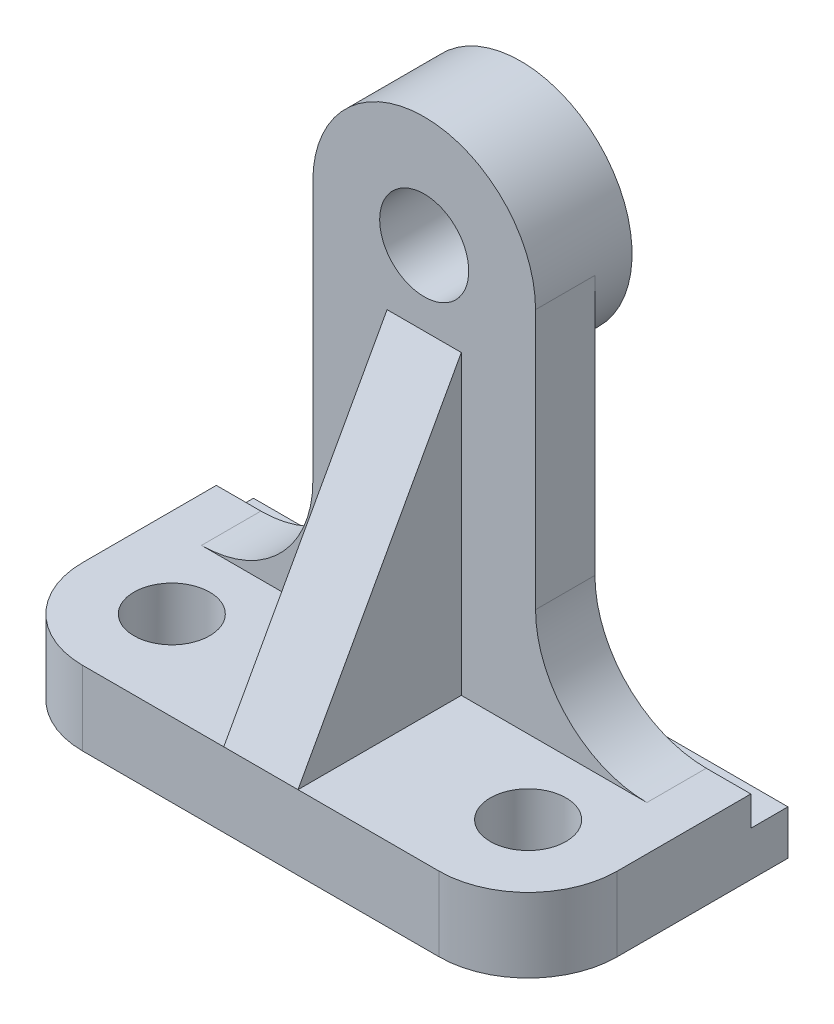
from build123d import *

# Parameters (mm, degrees)
SKETCH1_W           = 72
SKETCH1_H           = 35
BOSS_EXTRUDE1_DEPTH = 10
FILLET1_R           = 12
SKETCH2_W           = 5
SKETCH2_H           = 4
CUT_EXTRUDE1_DEPTH  = 75.767974428
SKETCH3_R           = 6
BOSS_EXTRUDE2_DEPTH = 8
FILLET2_R           = 15
FILLET3_R           = 15
M12_TAPPED_HOLE1_D  = 10.2
SKETCH7_R           = 15
SKETCH7_R_2         = 6
BOSS_EXTRUDE3_DEPTH = 5
RIB1_REACH          = 87.013
SKETCH8_WALL_W      = 217.67731737
SKETCH8_WALL_H      = 10


with BuildPart() as part:
    # Sketch1 → Boss-Extrude1 (new body)
    with BuildSketch(Plane(origin=(0, 0, 0), x_dir=(1, 0, 0), z_dir=(0, 1, 0))):
        Rectangle(SKETCH1_W, SKETCH1_H)
    extrude(amount=BOSS_EXTRUDE1_DEPTH)

    # Fillet1
    fillet1_edges = [part.edges().sort_by_distance(p)[0] for p in [
        (36, 5, 17.5),
        (-36, 5, 17.5),
    ]]
    fillet(fillet1_edges, radius=FILLET1_R)

    # Sketch2 → Cut-Extrude1 (cut, through all)
    with BuildSketch(Plane(origin=(36, 0, 0), x_dir=(0, 0, -1), z_dir=(1, 0, 0))):
        with Locations((15, 8)):
            Rectangle(SKETCH2_W, SKETCH2_H)
    extrude(amount=-CUT_EXTRUDE1_DEPTH, mode=Mode.SUBTRACT)

    # Sketch3 → Boss-Extrude2 (add)
    with BuildSketch(Plane(origin=(0, 0, -12.5), x_dir=(-1, 0, 0), z_dir=(0, 0, -1))):
        with BuildLine():
            Line((15, 10), (-15, 10))
            Line((-15, 10), (-15, 60))
            ThreePointArc((-15, 60), (0, 75), (15, 60))
            Line((15, 60), (15, 10))
        make_face()
        with Locations((0, 60)):
            Circle(SKETCH3_R, mode=Mode.SUBTRACT)
    extrude(amount=-BOSS_EXTRUDE2_DEPTH)

    # Fillet2
    fillet2_edges = [part.edges().sort_by_distance(p)[0] for p in [
        (15, 10, -8.5),
    ]]
    fillet(fillet2_edges, radius=FILLET2_R)

    # Fillet3
    fillet3_edges = [part.edges().sort_by_distance(p)[0] for p in [
        (-15, 10, -8.5),
    ]]
    fillet(fillet3_edges, radius=FILLET3_R)

    # M12 Tapped Hole1 (through all)
    with Locations(Plane(origin=(0, 10, 0), x_dir=(1, 0, 0), z_dir=(0, 1, 0))):
        with Locations((24, -5.5), (-24, -5.5)):
            Hole(M12_TAPPED_HOLE1_D / 2)

    # Sketch7 → Boss-Extrude3 (add)
    with BuildSketch(Plane(origin=(0, 0, -12.5), x_dir=(-1, 0, 0), z_dir=(0, 0, -1))):
        with Locations((0, 60)):
            Circle(SKETCH7_R)
        with Locations((0, 60)):
            Circle(SKETCH7_R_2, mode=Mode.SUBTRACT)
    extrude(amount=BOSS_EXTRUDE3_DEPTH)

    # Sketch8 wall → Rib1 (add, up to next)
    with BuildSketch(Plane(origin=(0, 30, 6.5), x_dir=(0, 0.876215908677, -0.481918749772), z_dir=(0, 0.481918749772, 0.876215908677)), mode=Mode.PRIVATE) as rib1_sk1:
        Rectangle(SKETCH8_WALL_W, SKETCH8_WALL_H)
    rib1_tool1 = extrude(rib1_sk1.sketch, amount=-RIB1_REACH, mode=Mode.PRIVATE) - part.part
    add(rib1_tool1.solids().sort_by_distance((0, 30, 6.5))[0])


solid = part.part
